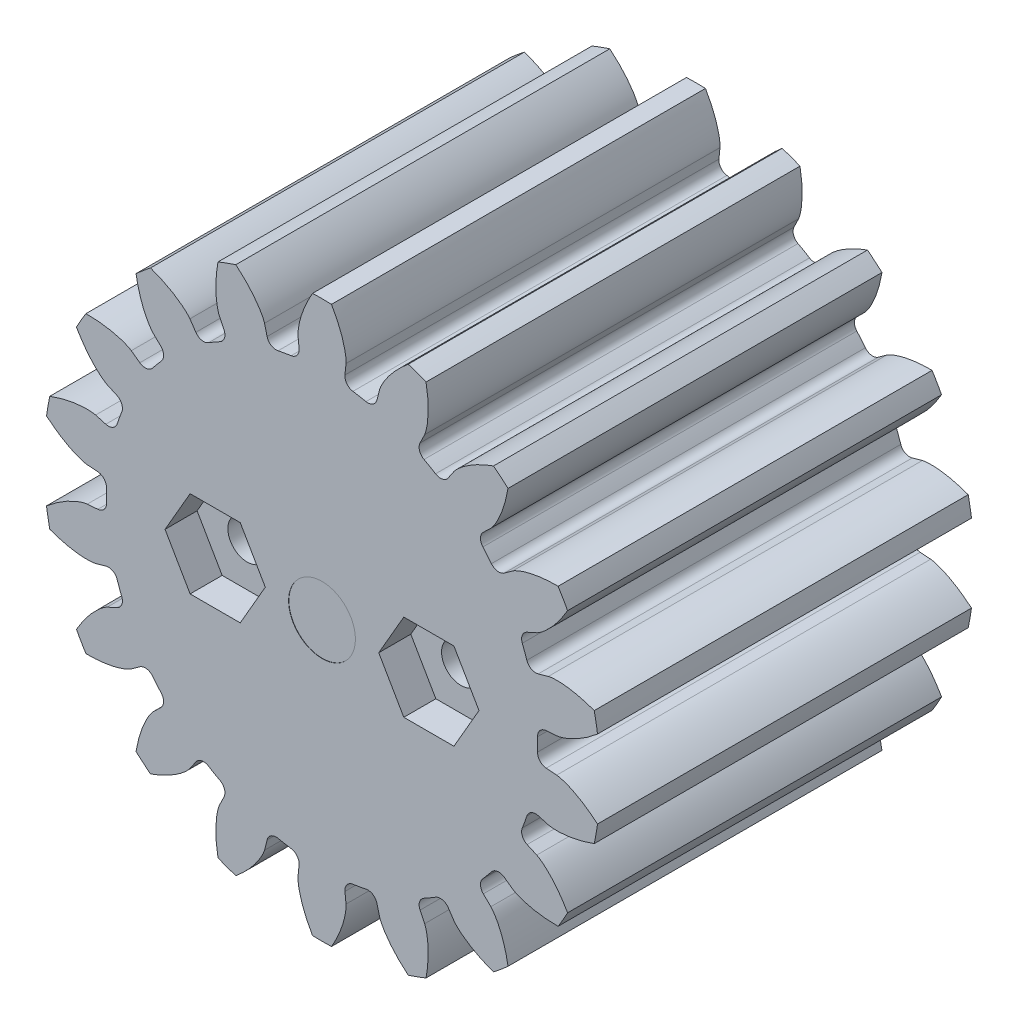
from build123d import *

# Parameters (mm, degrees)
SKETCH3_R                = 10.583333333
BOSS_EXTRUDE1_DEPTH      = 15.24
CUT_EXTRUDE1_START       = -16.24
CUT_EXTRUDE1_DEPTH       = 17.24
FILLET1_R                = 0.355076163
CIRPATTERN1_COUNT        = 18
FILLET1_OF_CIRPATTERN1_R = 0.355076163
SCALE3_SCALE             = 2.5
SKETCH10_R               = 3.175
CUT_EXTRUDE4_DEPTH       = 0.0254
SKETCH11_R               = 3.048
CUT_EXTRUDE5_DEPTH       = 8.636
CUT_EXTRUDE6_DEPTH       = 3.048
SKETCH14_R               = 1.8415
CUT_EXTRUDE7_DEPTH       = 12.7
SKETCH15_R               = 29.344199696
SKETCH15_R_2             = 8.89
CUT_EXTRUDE8_DEPTH       = 2.54


with BuildPart() as part:
    # Sketch3 → Boss-Extrude1 (new body)
    with BuildSketch(Plane.XY):
        Circle(SKETCH3_R)
    extrude(amount=-BOSS_EXTRUDE1_DEPTH)

    # Sketch4 → Cut-Extrude1 (cut)
    with BuildSketch(Plane.XY.offset(CUT_EXTRUDE1_START)):
        with BuildLine():
            Line((8.180618539, 0.593001964), (8.927148628, 0.647116919))
            add(Edge.make_bspline(
                [(8.927148628, 0.647116919), (8.929773603, 0.64734246), (8.937126743, 0.648083571), (8.950989701, 0.649913095), (8.97354406, 0.653505718), (9.002174883, 0.658974713), (9.039040294, 0.667064652), (9.08227108, 0.677905244), (9.129552823, 0.691187893), (9.180725702, 0.707111733), (9.231524372, 0.724296782), (9.281946361, 0.742644429), (9.331936661, 0.762005639), (9.392192531, 0.786734306), (9.464019144, 0.81815733), (9.547307729, 0.857451379), (9.640949476, 0.905033405), (9.735448155, 0.956729189), (9.827643658, 1.01022152), (9.919826595, 1.067258688), (10.008328253, 1.124562674), (10.099192996, 1.187113225), (10.182530598, 1.246394384), (10.274659666, 1.316128649), (10.348652098, 1.373376845), (10.424010343, 1.435256389), (10.460526963, 1.465776942), (10.479120716, 1.481544284)],
                knots=[0, 0, 0, 0, 0, 0.005376749, 0.015083688, 0.02853182, 0.04661014, 0.064854849, 0.092110526, 0.119476176, 0.146842496, 0.174208854, 0.201574956, 0.228941013, 0.256307345, 0.307035032, 0.361767352, 0.416499661, 0.471231937, 0.525964282, 0.580696616, 0.635428982, 0.690161387, 0.744893688, 0.799626082, 0.854358407, 0.909090915, 0.909090915, 0.909090915, 0.909090915, 0.909090915], degree=4))
            ThreePointArc((10.479120716, 1.481544284), (10.583333333, 0), (10.479120716, -1.481544284))
            add(Edge.make_bspline(
                [(8.927148628, -0.647116919), (8.929773603, -0.64734246), (8.937126743, -0.648083571), (8.950989701, -0.649913095), (8.97354406, -0.653505718), (9.002174883, -0.658974713), (9.039040294, -0.667064652), (9.08227108, -0.677905244), (9.129552823, -0.691187893), (9.180725702, -0.707111733), (9.231524372, -0.724296782), (9.281946361, -0.742644429), (9.331936661, -0.762005639), (9.392192531, -0.786734306), (9.464019144, -0.81815733), (9.547307729, -0.857451379), (9.640949476, -0.905033405), (9.735448155, -0.956729189), (9.827643658, -1.01022152), (9.919826595, -1.067258688), (10.008328253, -1.124562674), (10.099192996, -1.187113225), (10.182530598, -1.246394384), (10.274659666, -1.316128649), (10.348652098, -1.373376845), (10.424010343, -1.435256389), (10.460526963, -1.465776942), (10.479120716, -1.481544284)],
                knots=[0, 0, 0, 0, 0, 0.005376749, 0.015083688, 0.02853182, 0.04661014, 0.064854849, 0.092110526, 0.119476176, 0.146842496, 0.174208854, 0.201574956, 0.228941013, 0.256307345, 0.307035032, 0.361767352, 0.416499661, 0.471231937, 0.525964282, 0.580696616, 0.635428982, 0.690161387, 0.744893688, 0.799626082, 0.854358407, 0.909090915, 0.909090915, 0.909090915, 0.909090915, 0.909090915], degree=4))
            Line((8.927148628, -0.647116919), (8.180618539, -0.593001964))
            ThreePointArc((8.180618539, -0.593001964), (8.202083333, 0), (8.180618539, 0.593001964))
        make_face()
    cut_extrude1 = extrude(amount=CUT_EXTRUDE1_DEPTH, mode=Mode.SUBTRACT)

    # Fillet1
    fillet1_edges = [part.edges().sort_by_distance(p)[0] for p in [
        (8.180618539, -0.593001964, -7.62),
        (8.180618539, 0.593001964, -7.62),
    ]]
    fillet(fillet1_edges, radius=FILLET1_R)

    # CirPattern1: Cut-Extrude1 ×18 about axis
    cirpattern1_axis = Axis((0, 0, 6.35), (0, 0, -1))
    for i in range(1, CIRPATTERN1_COUNT):
        add(cut_extrude1.rotate(cirpattern1_axis, i * 360 / CIRPATTERN1_COUNT), mode=Mode.SUBTRACT)

    # Fillet1 of CirPattern1
    fillet1_of_cirpattern1_edges = [part.edges().sort_by_distance(p)[0] for p in [
        (7.484448258, -3.355175895, -7.62),
        (7.890085491, -2.240696756, -7.62),
        (5.885543058, -5.712666095, -7.62),
        (6.647891688, -4.804134377, -7.62),
        (3.576754504, -7.381124455, -7.62),
        (4.603864035, -6.788122491, -7.62),
        (0.83655657, -8.159310272, -7.62),
        (2.004542433, -7.953362851, -7.62),
        (-2.004542433, -7.953362851, -7.62),
        (-0.83655657, -8.159310272, -7.62),
        (-4.603864035, -6.788122491, -7.62),
        (-3.576754504, -7.381124455, -7.62),
        (-6.647891688, -4.804134377, -7.62),
        (-5.885543058, -5.712666095, -7.62),
        (-7.890085491, -2.240696756, -7.62),
        (-7.484448258, -3.355175895, -7.62),
        (-8.180618539, 0.593001964, -7.62),
        (-8.180618539, -0.593001964, -7.62),
        (-7.484448258, 3.355175895, -7.62),
        (-7.890085491, 2.240696756, -7.62),
        (-5.885543058, 5.712666095, -7.62),
        (-6.647891688, 4.804134377, -7.62),
        (-3.576754504, 7.381124455, -7.62),
        (-4.603864035, 6.788122491, -7.62),
        (-0.83655657, 8.159310272, -7.62),
        (-2.004542433, 7.953362851, -7.62),
        (2.004542433, 7.953362851, -7.62),
        (0.83655657, 8.159310272, -7.62),
        (4.603864035, 6.788122491, -7.62),
        (3.576754504, 7.381124455, -7.62),
        (6.647891688, 4.804134377, -7.62),
        (5.885543058, 5.712666095, -7.62),
        (7.890085491, 2.240696756, -7.62),
        (7.484448258, 3.355175895, -7.62),
    ]]
    fillet(fillet1_of_cirpattern1_edges, radius=FILLET1_OF_CIRPATTERN1_R)


with BuildPart() as part_1:
    # Scale3: scaled about (0, 0, 0)
    add(part.part.scale(SCALE3_SCALE))

    # Sketch10 → Cut-Extrude4 (cut)
    with BuildSketch(Plane.XY):
        Circle(SKETCH10_R)
    extrude(amount=-CUT_EXTRUDE4_DEPTH, mode=Mode.SUBTRACT)

    # Sketch11 → Cut-Extrude5 (cut)
    with BuildSketch(Plane(origin=(0, 0, -38.1), x_dir=(-1, 0, 0), z_dir=(0, 0, -1))):
        Circle(SKETCH11_R)
    extrude(amount=-CUT_EXTRUDE5_DEPTH, mode=Mode.SUBTRACT)

    # Sketch13 → Cut-Extrude6 (cut)
    with BuildSketch(Plane.XY):
        Polygon((-5.393973528, 0), (-7.776986764, 4.1275), (-12.543013236, 4.1275), (-14.926026472, 0), (-12.543013236, -4.1275), (-7.776986764, -4.1275), align=None)
        Polygon((14.926026472, 0), (12.543013236, 4.1275), (7.776986764, 4.1275), (5.393973528, 0), (7.776986764, -4.1275), (12.543013236, -4.1275), align=None)
    extrude(amount=-CUT_EXTRUDE6_DEPTH, mode=Mode.SUBTRACT)

    # Sketch14 → Cut-Extrude7 (cut)
    with BuildSketch(Plane.XY.offset(-3.048)):
        with Locations((-10.16, 0)):
            Circle(SKETCH14_R)
        with Locations((10.16, 0)):
            Circle(SKETCH14_R)
    extrude(amount=-CUT_EXTRUDE7_DEPTH, mode=Mode.SUBTRACT)

    # Sketch15 → Cut-Extrude8 (cut)
    with BuildSketch(Plane(origin=(0, 0, -38.1), x_dir=(-1, 0, 0), z_dir=(0, 0, -1))):
        Circle(SKETCH15_R)
        Circle(SKETCH15_R_2, mode=Mode.SUBTRACT)
    extrude(amount=-CUT_EXTRUDE8_DEPTH, mode=Mode.SUBTRACT)


solid = part_1.part
